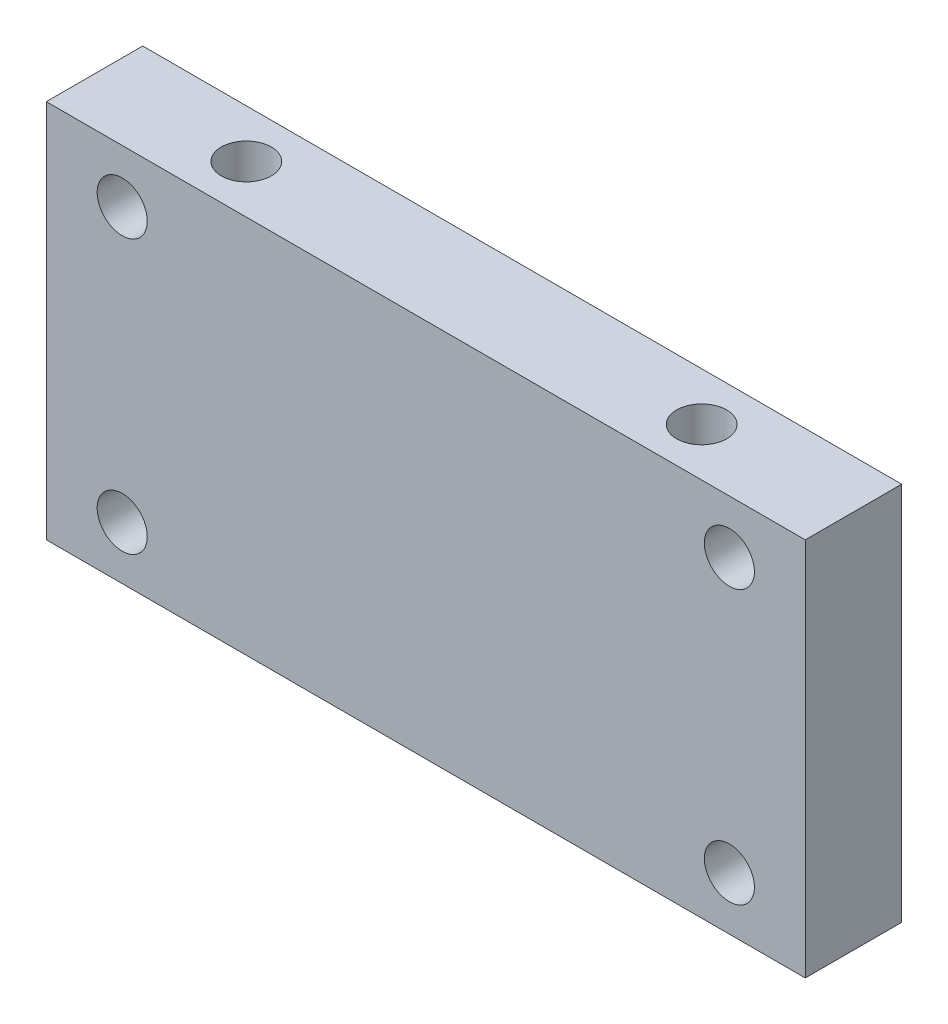
from build123d import *

# Parameters (mm, degrees)
SKETCH1_W                 = 50
SKETCH1_H                 = 6.35
BOSS_EXTRUDE1_DEPTH       = 25
M4X0_7_TAPPED_HOLE1_D     = 3.3
M4X0_7_TAPPED_HOLE1_DEPTH = 10.1
M4X0_7_TAPPED_HOLE1_TIP   = 0.991420021
M4X0_7_TAPPED_HOLE2_D     = 3.3
M4X0_7_TAPPED_HOLE2_DEPTH = 10.1
M4X0_7_TAPPED_HOLE2_TIP   = 0.991420021


with BuildPart() as part:
    # Sketch1 → Boss-Extrude1 (new body)
    with BuildSketch(Plane(origin=(0, 0, 0), x_dir=(1, 0, 0), z_dir=(0, 1, 0))):
        with Locations((25, 3.175)):
            Rectangle(SKETCH1_W, SKETCH1_H)
    extrude(amount=BOSS_EXTRUDE1_DEPTH)

    # M4x0.7 Tapped Hole1
    with Locations(Plane(origin=(40, 25, -3.175), x_dir=(0, 0, 1), z_dir=(0, 1, 0))):
        with Locations((0, 0), (0, -30)):
            Hole(M4X0_7_TAPPED_HOLE1_D / 2, depth=M4X0_7_TAPPED_HOLE1_DEPTH)
            with Locations((0, 0, -(M4X0_7_TAPPED_HOLE1_DEPTH + M4X0_7_TAPPED_HOLE1_TIP / 2))):  # 118° drill point
                Cone(0, M4X0_7_TAPPED_HOLE1_D / 2, M4X0_7_TAPPED_HOLE1_TIP, mode=Mode.SUBTRACT)

    # M4x0.7 Tapped Hole2
    with Locations(Plane(origin=(5, 21.5, 0), x_dir=(1, 0, 0), z_dir=(0, 0, 1))):
        with Locations((0, 0), (40, 0), (40, -18), (0, -18)):
            Hole(M4X0_7_TAPPED_HOLE2_D / 2, depth=M4X0_7_TAPPED_HOLE2_DEPTH)
            with Locations((0, 0, -(M4X0_7_TAPPED_HOLE2_DEPTH + M4X0_7_TAPPED_HOLE2_TIP / 2))):  # 118° drill point
                Cone(0, M4X0_7_TAPPED_HOLE2_D / 2, M4X0_7_TAPPED_HOLE2_TIP, mode=Mode.SUBTRACT)


solid = part.part
